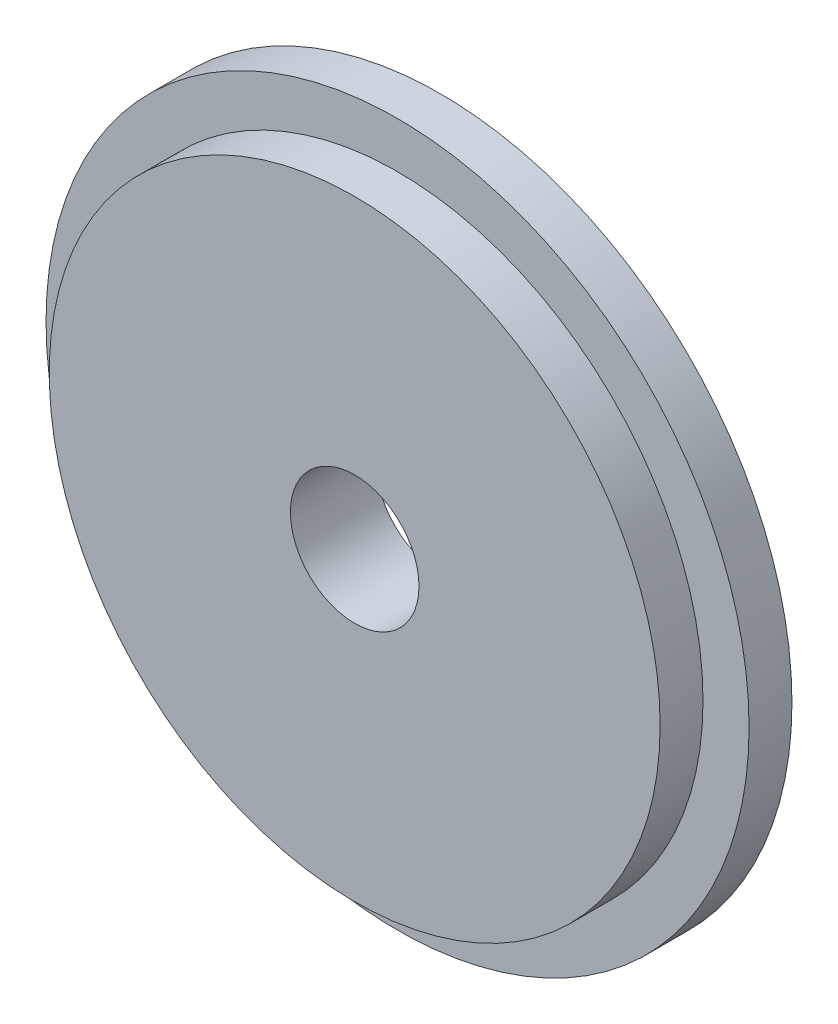
from build123d import *

# Parameters (mm, degrees)
ESQUISSE1_R             = 16.4
BOSS_EXTRU_1_DEPTH      = 2
ESQUISSE2_R             = 14.25
BOSS_EXTRU_2_DEPTH      = 2
ESQUISSE3_R             = 3
ENL_V_MAT_EXTRU_1_DEPTH = 5


with BuildPart() as part:
    # Esquisse1 → Boss.-Extru.1 (new body)
    with BuildSketch(Plane.XY):
        Circle(ESQUISSE1_R)
    extrude(amount=BOSS_EXTRU_1_DEPTH)

    # Esquisse2 → Boss.-Extru.2 (add)
    with BuildSketch(Plane.XY.offset(2)):
        Circle(ESQUISSE2_R)
    extrude(amount=BOSS_EXTRU_2_DEPTH)

    # Esquisse3 → Enlèv. mat.-Extru.1 (cut, through all)
    with BuildSketch(Plane.XY.offset(4)):
        Circle(ESQUISSE3_R)
    extrude(amount=-ENL_V_MAT_EXTRU_1_DEPTH, mode=Mode.SUBTRACT)


solid = part.part
